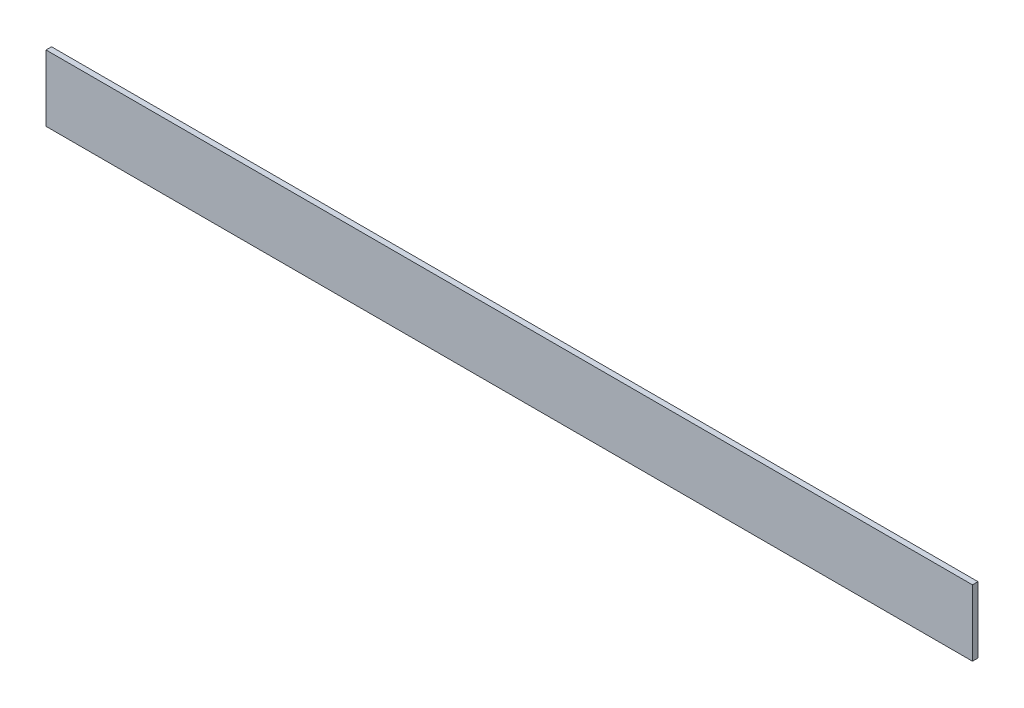
from build123d import *

# Parameters (mm, degrees)
SKETCH1_W           = 6.35
SKETCH1_H           = 76.2
BOSS_EXTRUDE1_DEPTH = 1066.8


with BuildPart() as part:
    # Sketch1 → Boss-Extrude1 (new body)
    with BuildSketch(Plane(origin=(0, 0, 0), x_dir=(0, 0, -1), z_dir=(1, 0, 0))):
        Rectangle(SKETCH1_W, SKETCH1_H)
    extrude(amount=BOSS_EXTRUDE1_DEPTH)


solid = part.part
